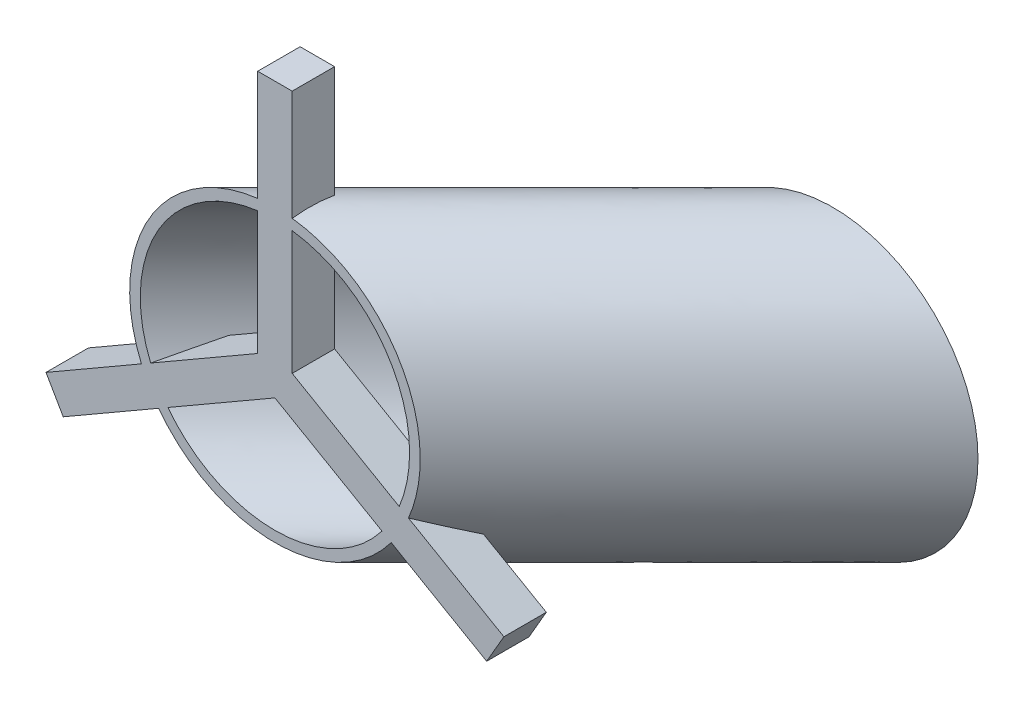
from build123d import *

# Parameters (mm, degrees)
ESQUISSE1_R                  = 13.7
ESQUISSE1_R_2                = 12.7
ESQUISSE3_W                  = 3.251730064
ESQUISSE3_H                  = 23.99378428
BOSS_EXTRU_1_DEPTH           = 4
R_P_TITION_CIRCULAIRE1_COUNT = 3


with BuildPart() as part:
    # Balayage1: sweep along a path in Esquisse2
    with BuildLine(Plane(origin=(0, 0, 0), x_dir=(1, 0, 0), z_dir=(0, 1, 0))) as balayage1_path:
        Line((0, 0), (26.30360969, 26.30360969))
    # Esquisse1 → Balayage1 (sweep)
    with BuildSketch(Plane.XY):
        Circle(ESQUISSE1_R)
        Circle(ESQUISSE1_R_2, mode=Mode.SUBTRACT)
    sweep(path=balayage1_path.line)

    # Esquisse3 → Boss.-Extru.1 (add)
    with BuildSketch(Plane.XY):
        with Locations((0, 11.99689214)):
            Rectangle(ESQUISSE3_W, ESQUISSE3_H)
    boss_extru_1 = extrude(amount=-BOSS_EXTRU_1_DEPTH)

    # Répétition circulaire1: Boss.-Extru.1 ×3 about axis
    r_p_tition_circulaire1_axis = Axis((0, 0, 0), (0, 0, 1))
    for i in range(1, R_P_TITION_CIRCULAIRE1_COUNT):
        add(boss_extru_1.rotate(r_p_tition_circulaire1_axis, i * 360 / R_P_TITION_CIRCULAIRE1_COUNT))


solid = part.part
